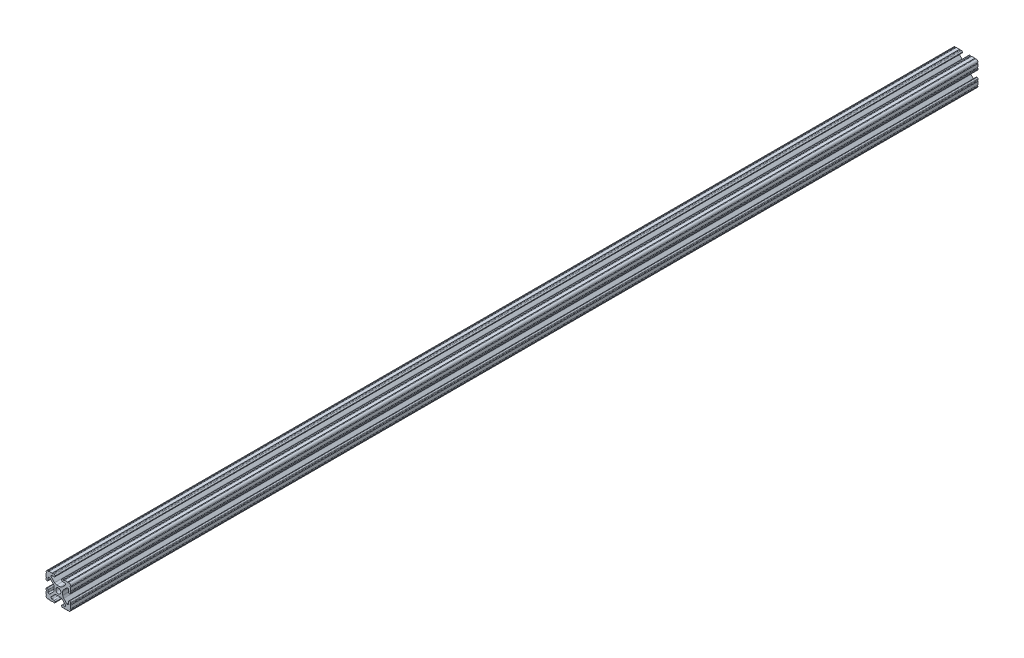
from build123d import *

# Parameters (mm, degrees)
SKETCH1_R               = 2.6035
BOSS_EXTRUDE1_DEPTH     = 466.725
SKETCH2_R               = 3.175
CUT_EXTRUDE1_DEPTH      = 9.1915
CUT_EXTRUDE1_DEPTH_BACK = 18.2085


with BuildPart() as part:
    # Sketch1 → Boss-Extrude1 (new body, symmetric)
    with BuildSketch(Plane.XY):
        with BuildLine():
            Line((-7.179650497, -8.645192506), (-3.952270251, -5.423690499))
            ThreePointArc((-3.952270251, -5.423690499), (-2.922936451, -4.736929036), (-1.709253557, -4.4958))
            Line((-1.709253557, -4.4958), (1.709253557, -4.4958))
            ThreePointArc((1.709253557, -4.4958), (2.922936451, -4.736929036), (3.952270251, -5.423690499))
            Line((3.952270251, -5.423690499), (7.179650497, -8.645192506))
            ThreePointArc((7.179650497, -8.645192506), (7.41473083, -9.822813117), (6.416408329, -10.4902))
            Line((6.416408329, -10.4902), (4.287512407, -10.4902))
            ThreePointArc((4.287512407, -10.4902), (3.54574862, -10.79744862), (3.2385, -11.539212407))
            Line((3.2385, -11.539212407), (3.2385, -11.650987593))
            ThreePointArc((3.2385, -11.650987593), (3.54574862, -12.39275138), (4.287512407, -12.7))
            Line((4.287512407, -12.7), (5.317126718, -12.7))
            ThreePointArc((5.317126718, -12.7), (5.825126718, -12.192), (6.333126718, -12.7))
            Line((6.333126718, -12.7), (9.550443118, -12.7))
            ThreePointArc((9.550443118, -12.7), (10.058366869, -12.192000006), (10.566443095, -12.699847501))
            ThreePointArc((10.566443095, -12.699847501), (12.082537762, -12.08250727), (12.699846982, -10.566399977))
            ThreePointArc((12.699846982, -10.566399977), (12.192000006, -10.058323491), (12.7, -9.5504))
            Line((12.7, -9.5504), (12.7, -6.3330836))
            ThreePointArc((12.7, -6.3330836), (12.192, -5.8250836), (12.7, -5.3170836))
            Line((12.7, -5.3170836), (12.7, -4.287469289))
            ThreePointArc((12.7, -4.287469289), (12.39275138, -3.545705502), (11.650987593, -3.238456882))
            Line((11.650987593, -3.238456882), (11.539212407, -3.238456882))
            ThreePointArc((11.539212407, -3.238456882), (10.79744862, -3.545705502), (10.4902, -4.287469289))
            Line((10.4902, -4.287469289), (10.4902, -6.402089023))
            ThreePointArc((10.4902, -6.402089023), (9.856505071, -7.351067942), (8.737131347, -7.129408934))
            Line((8.737131347, -7.129408934), (5.441005833, -3.840816462))
            ThreePointArc((5.441005833, -3.840816462), (4.750877967, -2.809883091), (4.5085, -1.593185507))
            Line((4.5085, -1.593185507), (4.5085, 1.593185507))
            ThreePointArc((4.5085, 1.593185507), (4.750877967, 2.809883091), (5.441005833, 3.840816462))
            Line((5.441005833, 3.840816462), (8.737131347, 7.129408934))
            ThreePointArc((8.737131347, 7.129408934), (9.856505071, 7.351067942), (10.4902, 6.402089023))
            Line((10.4902, 6.402089023), (10.4902, 4.287469289))
            ThreePointArc((10.4902, 4.287469289), (10.79744862, 3.545705502), (11.539212407, 3.238456882))
            Line((11.539212407, 3.238456882), (11.650987593, 3.238456882))
            ThreePointArc((11.650987593, 3.238456882), (12.39275138, 3.545705502), (12.7, 4.287469289))
            Line((12.7, 4.287469289), (12.7, 5.3170836))
            ThreePointArc((12.7, 5.3170836), (12.192, 5.8250836), (12.7, 6.3330836))
            Line((12.7, 6.3330836), (12.7, 9.5504))
            ThreePointArc((12.7, 9.5504), (12.192000006, 10.058323491), (12.699846982, 10.566399977))
            ThreePointArc((12.699846982, 10.566399977), (12.082537762, 12.08250727), (10.566443095, 12.699847501))
            ThreePointArc((10.566443095, 12.699847501), (10.058366869, 12.192000006), (9.550443118, 12.7))
            Line((9.550443118, 12.7), (6.333126718, 12.7))
            ThreePointArc((6.333126718, 12.7), (5.825126718, 12.192), (5.317126718, 12.7))
            Line((5.317126718, 12.7), (4.287512407, 12.7))
            ThreePointArc((4.287512407, 12.7), (3.54574862, 12.39275138), (3.2385, 11.650987593))
            Line((3.2385, 11.650987593), (3.2385, 11.539212407))
            ThreePointArc((3.2385, 11.539212407), (3.54574862, 10.79744862), (4.287512407, 10.4902))
            Line((4.287512407, 10.4902), (6.476788598, 10.4902))
            ThreePointArc((6.476788598, 10.4902), (7.432222385, 9.85140422), (7.207036008, 8.724370562))
            Line((7.207036008, 8.724370562), (3.898272566, 5.423169045))
            ThreePointArc((3.898272566, 5.423169045), (2.869120213, 4.736787962), (1.655778399, 4.4958))
            Line((1.655778399, 4.4958), (-1.655778399, 4.4958))
            ThreePointArc((-1.655778399, 4.4958), (-2.869120213, 4.736787962), (-3.898272566, 5.423169045))
            Line((-3.898272566, 5.423169045), (-7.207036008, 8.724370562))
            ThreePointArc((-7.207036008, 8.724370562), (-7.432222385, 9.85140422), (-6.476788598, 10.4902))
            Line((-6.476788598, 10.4902), (-4.287512407, 10.4902))
            ThreePointArc((-4.287512407, 10.4902), (-3.54574862, 10.79744862), (-3.2385, 11.539212407))
            Line((-3.2385, 11.539212407), (-3.2385, 11.650987593))
            ThreePointArc((-3.2385, 11.650987593), (-3.54574862, 12.39275138), (-4.287512407, 12.7))
            Line((-4.287512407, 12.7), (-5.317126718, 12.7))
            ThreePointArc((-5.317126718, 12.7), (-5.825126718, 12.192), (-6.333126718, 12.7))
            Line((-6.333126718, 12.7), (-9.550443118, 12.7))
            ThreePointArc((-9.550443118, 12.7), (-10.058366869, 12.192000006), (-10.566443095, 12.699847501))
            ThreePointArc((-10.566443095, 12.699847501), (-12.082537762, 12.08250727), (-12.699846982, 10.566399977))
            ThreePointArc((-12.699846982, 10.566399977), (-12.192000006, 10.058323491), (-12.7, 9.5504))
            Line((-12.7, 9.5504), (-12.7, 6.3330836))
            ThreePointArc((-12.7, 6.3330836), (-12.192, 5.8250836), (-12.7, 5.3170836))
            Line((-12.7, 5.3170836), (-12.7, 4.287469289))
            ThreePointArc((-12.7, 4.287469289), (-12.39275138, 3.545705502), (-11.650987593, 3.238456882))
            Line((-11.650987593, 3.238456882), (-11.539212407, 3.238456882))
            ThreePointArc((-11.539212407, 3.238456882), (-10.79744862, 3.545705502), (-10.4902, 4.287469289))
            Line((-10.4902, 4.287469289), (-10.4902, 6.402089023))
            ThreePointArc((-10.4902, 6.402089023), (-9.856505071, 7.351067942), (-8.737131347, 7.129408934))
            Line((-8.737131347, 7.129408934), (-5.441005833, 3.840816462))
            ThreePointArc((-5.441005833, 3.840816462), (-4.750877967, 2.809883091), (-4.5085, 1.593185507))
            Line((-4.5085, 1.593185507), (-4.5085, -1.593185507))
            ThreePointArc((-4.5085, -1.593185507), (-4.750877967, -2.809883091), (-5.441005833, -3.840816462))
            Line((-5.441005833, -3.840816462), (-8.737131347, -7.129408934))
            ThreePointArc((-8.737131347, -7.129408934), (-9.856505071, -7.351067942), (-10.4902, -6.402089023))
            Line((-10.4902, -6.402089023), (-10.4902, -4.287469289))
            ThreePointArc((-10.4902, -4.287469289), (-10.79744862, -3.545705502), (-11.539212407, -3.238456882))
            Line((-11.539212407, -3.238456882), (-11.650987593, -3.238456882))
            ThreePointArc((-11.650987593, -3.238456882), (-12.39275138, -3.545705502), (-12.7, -4.287469289))
            Line((-12.7, -4.287469289), (-12.7, -5.3170836))
            ThreePointArc((-12.7, -5.3170836), (-12.192, -5.8250836), (-12.7, -6.3330836))
            Line((-12.7, -6.3330836), (-12.7, -9.5504))
            ThreePointArc((-12.7, -9.5504), (-12.192000006, -10.058323491), (-12.699846982, -10.566399977))
            ThreePointArc((-12.699846982, -10.566399977), (-12.082537762, -12.08250727), (-10.566443095, -12.699847501))
            ThreePointArc((-10.566443095, -12.699847501), (-10.058366869, -12.192000006), (-9.550443118, -12.7))
            Line((-9.550443118, -12.7), (-6.333126718, -12.7))
            ThreePointArc((-6.333126718, -12.7), (-5.825126718, -12.192), (-5.317126718, -12.7))
            Line((-5.317126718, -12.7), (-4.287512407, -12.7))
            ThreePointArc((-4.287512407, -12.7), (-3.54574862, -12.39275138), (-3.2385, -11.650987593))
            Line((-3.2385, -11.650987593), (-3.2385, -11.539212407))
            ThreePointArc((-3.2385, -11.539212407), (-3.54574862, -10.79744862), (-4.287512407, -10.4902))
            Line((-4.287512407, -10.4902), (-6.416408329, -10.4902))
            ThreePointArc((-6.416408329, -10.4902), (-7.41473083, -9.822813117), (-7.179650497, -8.645192506))
        make_face()
        Circle(SKETCH1_R, mode=Mode.SUBTRACT)
    extrude(amount=BOSS_EXTRUDE1_DEPTH, both=True)

    # Sketch2 → Cut-Extrude1 (cut, two sides)
    with BuildSketch(Plane(origin=(4.5085, 0, 0), x_dir=(0, 0, -1), z_dir=(1, 0, 0))) as cut_extrude1_sk:
        with Locations((-282.575, 0)):
            Circle(SKETCH2_R)
        with Locations((282.575, 0)):
            Circle(SKETCH2_R)
        with Locations((-85.725, 0)):
            Circle(SKETCH2_R)
        with Locations((85.725, 0)):
            Circle(SKETCH2_R)
    extrude(amount=CUT_EXTRUDE1_DEPTH, mode=Mode.SUBTRACT)
    extrude(cut_extrude1_sk.sketch, amount=-CUT_EXTRUDE1_DEPTH_BACK, mode=Mode.SUBTRACT)


solid = part.part
